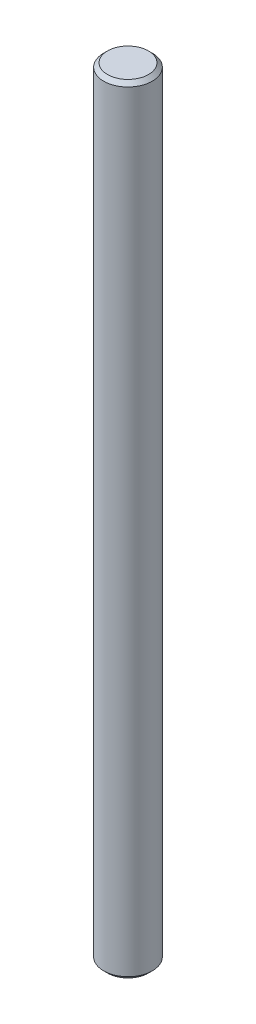
from build123d import *

# Parameters (mm, degrees)
BAR_FACE_R        = 3.175
BAR_EXTRUDE_DEPTH = 101.6
CHAMFER2_SIZE     = 0.5


with BuildPart() as part:
    # Bar face → Bar extrude (new body)
    with BuildSketch(Plane(origin=(0, 0, 0), x_dir=(1, 0, 0), z_dir=(0, 1, 0))):
        Circle(BAR_FACE_R)
    extrude(amount=BAR_EXTRUDE_DEPTH)

    # Chamfer2
    chamfer2_edges = [part.edges().sort_by_distance(p)[0] for p in [
        (-3.175, 0, 0),
        (-3.175, 101.6, 0),
    ]]
    chamfer(chamfer2_edges, length=CHAMFER2_SIZE)


solid = part.part
